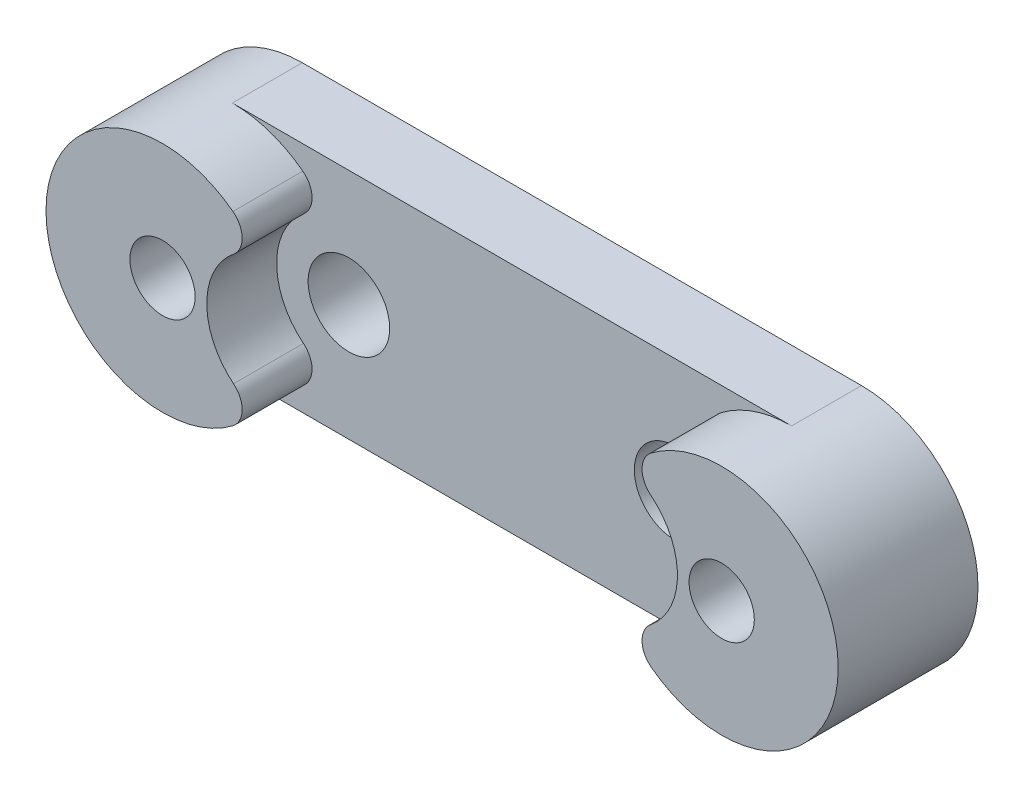
from build123d import *
from build123d.topology import SkipClean

# Parameters (mm, degrees)
SKETCH1_R                = 1.75
BOSS_EXTRUDE1_DEPTH      = 3
BOSS_EXTRUDE2_DEPTH      = 3
BOSS_EXTRUDE2_DEPTH_BACK = 3
SKETCH2_R                = 1.4
FILLET1_R                = 1


with BuildPart() as part:
    # Sketch1 → Boss-Extrude1 (new body)
    with BuildSketch(Plane.XY):
        with BuildLine():
            Line((-12, 5), (12, 5))
            ThreePointArc((12, 5), (17, 0), (12, -5))
            Line((12, -5), (-12, -5))
            ThreePointArc((-12, -5), (-17, 0), (-12, 5))
        make_face()
        with Locations((-7, 0)):
            Circle(SKETCH1_R, mode=Mode.SUBTRACT)
        with Locations((-12, 0)):
            Circle(SKETCH1_R, mode=Mode.SUBTRACT)
        with Locations((12, 0)):
            Circle(SKETCH1_R, mode=Mode.SUBTRACT)
        with Locations((7, 0)):
            Circle(SKETCH1_R, mode=Mode.SUBTRACT)
    extrude(amount=BOSS_EXTRUDE1_DEPTH)

    # Sketch2 → Boss-Extrude2 (add, two sides: drawn at the far end of the back side and taken through both)
    # profile 1 of 2: a face of its own
    with SkipClean():  # the faces are left unmerged after this step: merging them gives an invalid solid
        with BuildSketch(Plane.XY.offset(3).offset(-BOSS_EXTRUDE2_DEPTH_BACK)):
            with BuildLine():
                ThreePointArc((-7.961, 2.947283), (-17, 0), (-7.961, -2.947283))
                ThreePointArc((-7.961, -2.947283), (-10.1, 0), (-7.961, 2.947283))
            make_face()
            with Locations((-12, 0)):
                Circle(SKETCH2_R, mode=Mode.SUBTRACT)
        # profile 2 of 2: a face of its own
        with BuildSketch(Plane.XY.offset(3).offset(-BOSS_EXTRUDE2_DEPTH_BACK)):
            with BuildLine():
                ThreePointArc((7.961, 2.947283), (10.1, 0), (7.961, -2.947283))
                ThreePointArc((7.961, -2.947283), (17, 0), (7.961, 2.947283))
            make_face()
            with Locations((12, 0)):
                Circle(SKETCH2_R, mode=Mode.SUBTRACT)
        extrude(amount=BOSS_EXTRUDE2_DEPTH + BOSS_EXTRUDE2_DEPTH_BACK)

    # Fillet1
    fillet1_edges = [part.edges().sort_by_distance(p)[0] for p in [
        (7.961, 2.947283, 4.5),
        (7.961, -2.947283, 4.5),
        (-7.961, -2.947283, 4.5),
        (-7.961, 2.947283, 4.5),
    ]]
    fillet(fillet1_edges, radius=FILLET1_R)


solid = part.part
